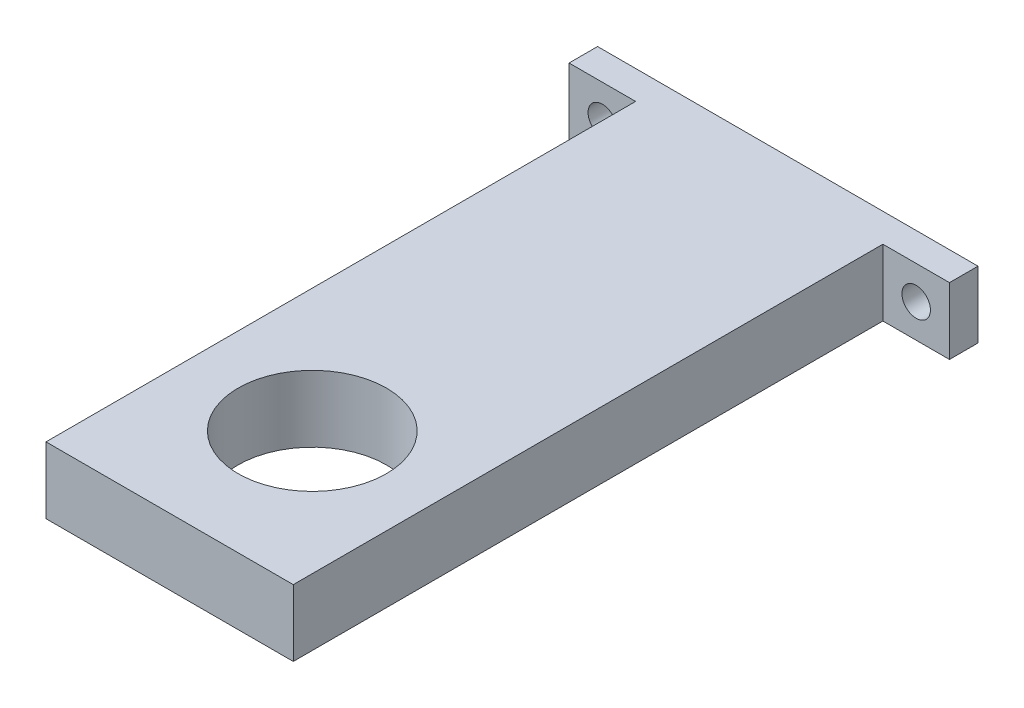
from build123d import *

# Parameters (mm, degrees)
SKETCH_1_W          = 40
SKETCH_1_H          = 7
EXTRUDE_1_DEPTH     = 3
SKETCH_2_W          = 26
SKETCH_2_H          = 7
EXTRUDE_2_DEPTH     = 62
SKETCH_3_R          = 7.8
CUT_EXTRUDE_1_DEPTH = 7
SKETCH_4_R          = 1.5
CUT_EXTRUDE_2_DEPTH = 7
SKETCH_5_R          = 1.5
CUT_EXTRUDE_3_DEPTH = 7


with BuildPart() as part:
    # Эскиз1 → Бобышка-Вытянуть1 (new body)
    with BuildSketch(Plane.XY):
        Rectangle(SKETCH_1_W, SKETCH_1_H)
    extrude(amount=EXTRUDE_1_DEPTH)

    # Эскиз2 → Бобышка-Вытянуть2 (add)
    with BuildSketch(Plane.XY.offset(3)):
        Rectangle(SKETCH_2_W, SKETCH_2_H)
    extrude(amount=EXTRUDE_2_DEPTH)

    # Эскиз3 → Вырез-Вытянуть1 (cut)
    with BuildSketch(Plane(origin=(0, -3.5, 0), x_dir=(-1, 0, 0), z_dir=(0, -1, 0))):
        with Locations((0, -50)):
            Circle(SKETCH_3_R)
    extrude(amount=-CUT_EXTRUDE_1_DEPTH, mode=Mode.SUBTRACT)

    # Эскиз4 → Вырез-Вытянуть2 (cut)
    with BuildSketch(Plane.XY.offset(3)):
        with Locations((-16.5, 0)):
            Circle(SKETCH_4_R)
    extrude(amount=-CUT_EXTRUDE_2_DEPTH, mode=Mode.SUBTRACT)

    # Эскиз5 → Вырез-Вытянуть3 (cut)
    with BuildSketch(Plane.XY.offset(3)):
        with Locations((16.5, 0)):
            Circle(SKETCH_5_R)
    extrude(amount=-CUT_EXTRUDE_3_DEPTH, mode=Mode.SUBTRACT)


solid = part.part
